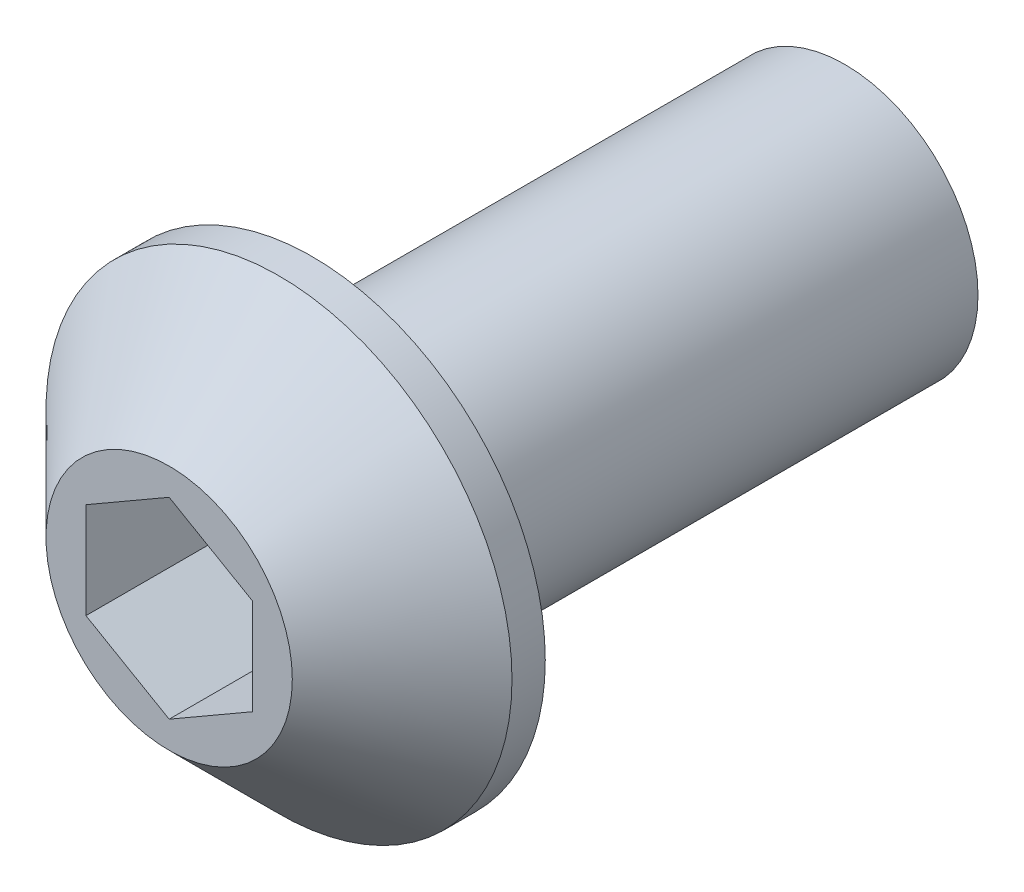
from build123d import *

# Parameters (mm, degrees)
SKETCH1_R           = 7
BASE_EXTRUDE_DEPTH  = 4.3
SKETCH2_R           = 4
BOSS_EXTRUDE1_DEPTH = 16
CUT_EXTRUDE1_DEPTH  = 4.3
CHAMFER1_SIZE       = 3.3


with BuildPart() as part:
    # Sketch1 → Base-Extrude (new body)
    with BuildSketch(Plane.XY):
        Circle(SKETCH1_R)
    extrude(amount=BASE_EXTRUDE_DEPTH)

    # Sketch2 → Boss-Extrude1 (add)
    with BuildSketch(Plane(origin=(0, 0, 0), x_dir=(-1, 0, 0), z_dir=(0, 0, -1))):
        Circle(SKETCH2_R)
    extrude(amount=BOSS_EXTRUDE1_DEPTH)

    # Sketch3 → Cut-Extrude1 (cut)
    with BuildSketch(Plane.XY.offset(4.3)):
        Polygon((0, 2.886751346), (-2.5, 1.443375673), (-2.5, -1.443375673), (0, -2.886751346), (2.5, -1.443375673), (2.5, 1.443375673), align=None)
    extrude(amount=-CUT_EXTRUDE1_DEPTH, mode=Mode.SUBTRACT)

    # Chamfer1
    chamfer1_edges = [part.edges().sort_by_distance(p)[0] for p in [
        (-7, 0, 4.3),
    ]]
    chamfer(chamfer1_edges, length=CHAMFER1_SIZE)


solid = part.part
